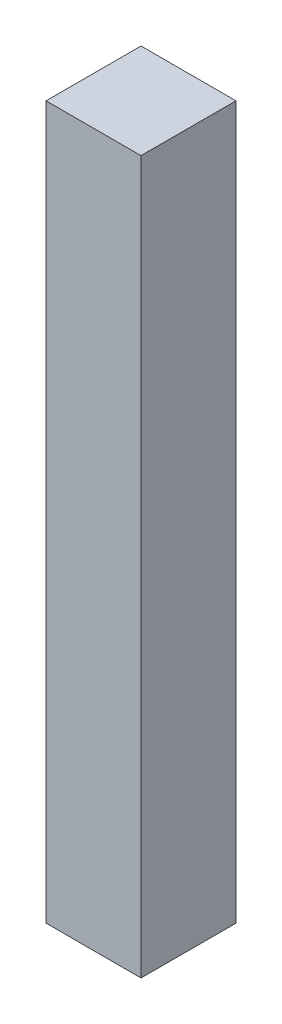
from build123d import *

# Parameters (mm, degrees)
SKETCH1_W           = 5.08
SKETCH1_H           = 5.08
BOSS_EXTRUDE2_DEPTH = 38.1


with BuildPart() as part:
    # Sketch1 → Boss-Extrude2 (new body)
    with BuildSketch(Plane(origin=(0, 0, 0), x_dir=(1, 0, 0), z_dir=(0, 1, 0))):
        Rectangle(SKETCH1_W, SKETCH1_H)
    extrude(amount=BOSS_EXTRUDE2_DEPTH)


solid = part.part
